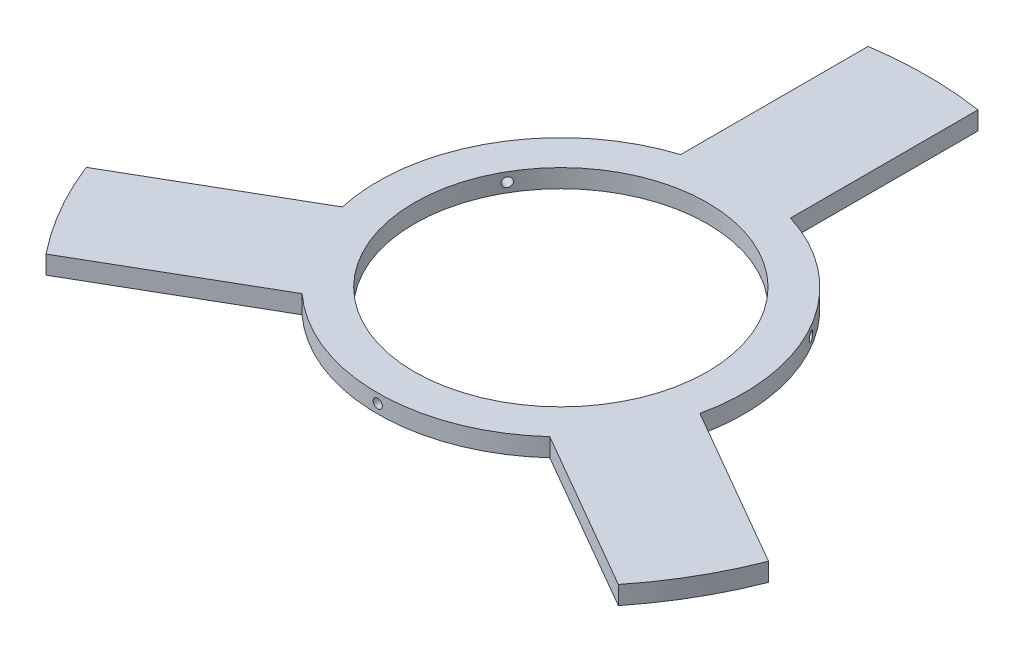
from build123d import *

# Parameters (mm, degrees)
SKETCH1_R           = 50.8
BOSS_EXTRUDE1_DEPTH = 6.35
SKETCH2_R           = 1.5875
CUT_EXTRUDE1_DEPTH  = 12.724811
CIRPATTERN1_COUNT   = 3


with BuildPart() as part:
    # Sketch1 → Boss-Extrude1 (new body)
    with BuildSketch(Plane(origin=(0, 0, 0), x_dir=(1, 0, 0), z_dir=(0, 1, 0))):
        with BuildLine():
            Line((-19.05, 112.701319868), (-19.05, 60.57513929))
            ThreePointArc((-19.05, 60.57513929), (-54.99261314, 31.75), (-61.984609463, -13.789785703))
            Line((-61.984609463, -13.789785703), (-107.127206046, -39.852875992))
            Line((-107.127206046, -39.852875992), (-118.265853064, -46.283776846))
            ThreePointArc((-118.265853064, -46.283776846), (-109.985226281, -63.5), (-99.215853064, -79.27934473))
            Line((-99.215853064, -79.27934473), (-88.077206046, -72.848443876))
            Line((-88.077206046, -72.848443876), (-42.934609463, -46.785353587))
            ThreePointArc((-42.934609463, -46.785353587), (0, -63.5), (42.934609463, -46.785353587))
            Line((42.934609463, -46.785353587), (88.077206046, -72.848443876))
            Line((88.077206046, -72.848443876), (99.215853064, -79.27934473))
            ThreePointArc((99.215853064, -79.27934473), (109.985226281, -63.5), (118.265853064, -46.283776846))
            Line((118.265853064, -46.283776846), (107.127206046, -39.852875992))
            Line((107.127206046, -39.852875992), (61.984609463, -13.789785703))
            ThreePointArc((61.984609463, -13.789785703), (54.99261314, 31.75), (19.05, 60.57513929))
            Line((19.05, 60.57513929), (19.05, 112.701319868))
            Line((19.05, 112.701319868), (19.05, 125.563121576))
            ThreePointArc((19.05, 125.563121576), (0, 127), (-19.05, 125.563121576))
            Line((-19.05, 125.563121576), (-19.05, 112.701319868))
        make_face()
        with Locations(Location((0, 0, 0), (0, 0, 270))):  # turned: the seam where the file's is
            Circle(SKETCH1_R, mode=Mode.SUBTRACT)
    extrude(amount=BOSS_EXTRUDE1_DEPTH)

    # Sketch2 → Cut-Extrude1 (cut)
    with BuildSketch(Plane.XY.offset(63.5)):
        with Locations((0, 3.175)):
            Circle(SKETCH2_R)
    cut_extrude1 = extrude(amount=-CUT_EXTRUDE1_DEPTH, mode=Mode.SUBTRACT)

    # CirPattern1: Cut-Extrude1 ×3 about axis
    cirpattern1_axis = Axis((0, 0, 0), (0, -1, 0))
    for i in range(1, CIRPATTERN1_COUNT):
        add(cut_extrude1.rotate(cirpattern1_axis, i * 360 / CIRPATTERN1_COUNT), mode=Mode.SUBTRACT)


solid = part.part
